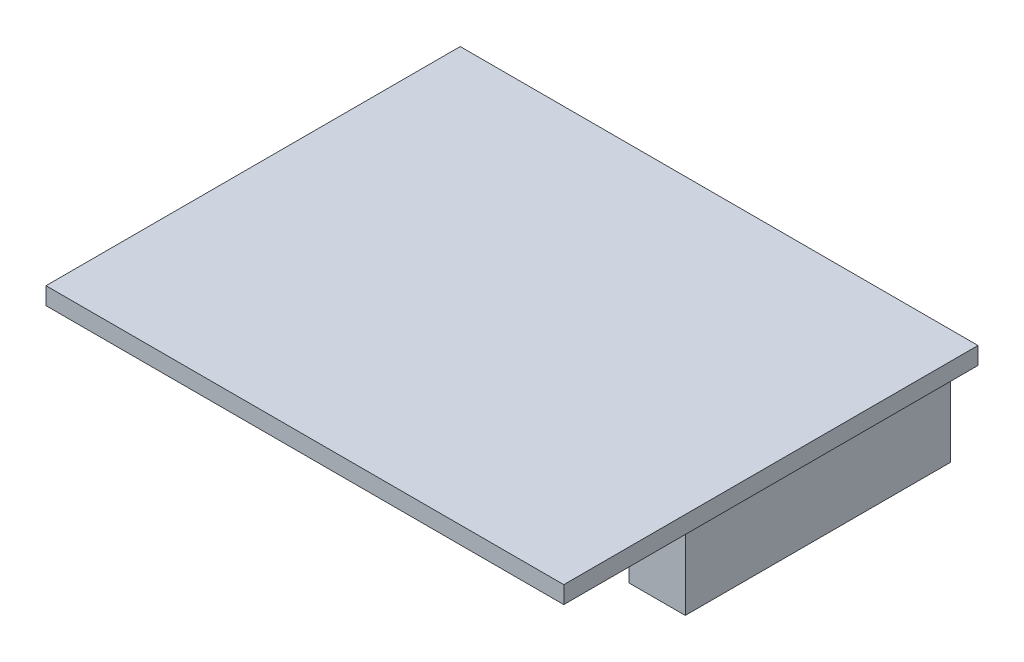
from build123d import *

# Parameters (mm, degrees)
SKETCH1_W           = 50.8
SKETCH1_H           = 40.64
BOSS_EXTRUDE1_DEPTH = 1.7
SKETCH2_W           = 5
SKETCH2_H           = 26
BOSS_EXTRUDE2_DEPTH = 8.6
SKETCH3_W           = 5.5
SKETCH3_H           = 26
BOSS_EXTRUDE3_DEPTH = 8.6


with BuildPart() as part:
    # Sketch1 → Boss-Extrude1 (new body)
    with BuildSketch(Plane(origin=(0, 0, 0), x_dir=(1, 0, 0), z_dir=(0, 1, 0))):
        Rectangle(SKETCH1_W, SKETCH1_H)
    extrude(amount=BOSS_EXTRUDE1_DEPTH)

    # Sketch2 → Boss-Extrude2 (add)
    with BuildSketch(Plane.XZ):
        with Locations((-21.9, -6.32)):
            Rectangle(SKETCH2_W, SKETCH2_H)
    extrude(amount=BOSS_EXTRUDE2_DEPTH)

    # Sketch3 → Boss-Extrude3 (add)
    with BuildSketch(Plane.XZ):
        with Locations((20.93, -6.32)):
            Rectangle(SKETCH3_W, SKETCH3_H)
    extrude(amount=BOSS_EXTRUDE3_DEPTH)


solid = part.part
